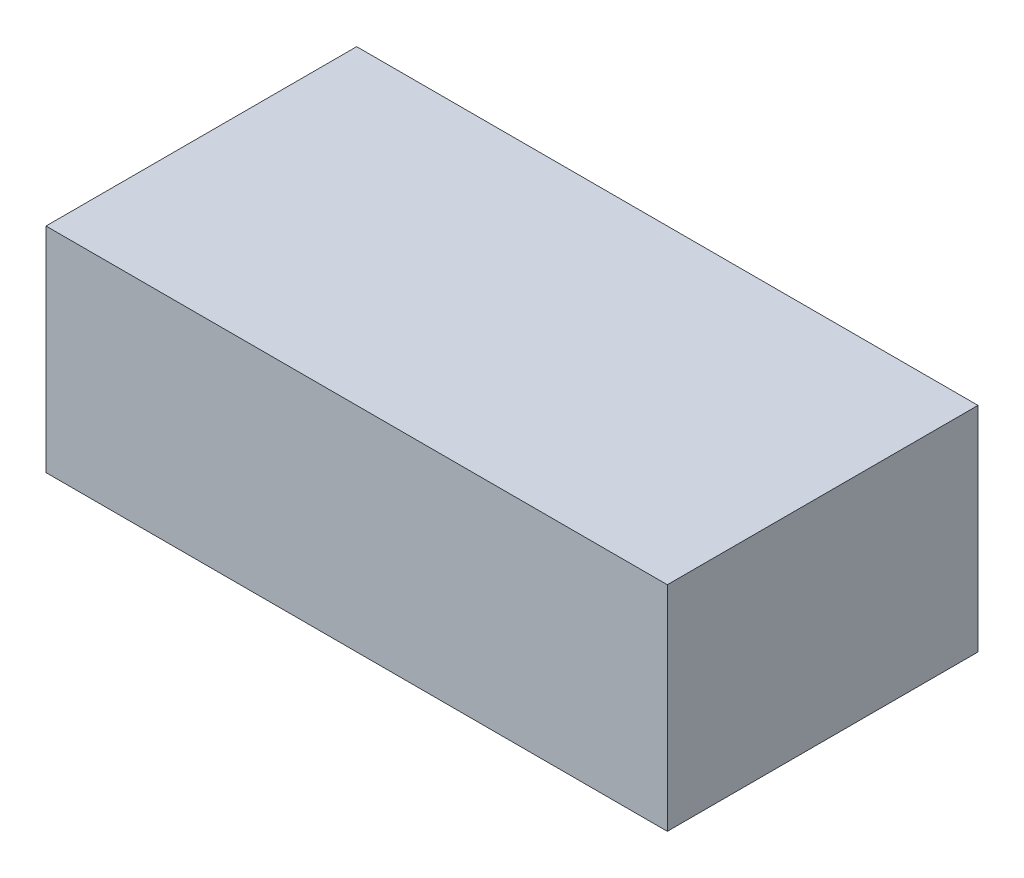
from build123d import *

# Parameters (mm, degrees)
BASES_W    = 1.6
BASES_H    = 0.8
BASE_DEPTH = 0.55


with BuildPart() as part:
    # BaseS → Base (new body)
    with BuildSketch(Plane(origin=(0, 0, 0), x_dir=(1, 0, 0), z_dir=(0, 1, 0))):
        Rectangle(BASES_W, BASES_H)
    extrude(amount=BASE_DEPTH)


solid = part.part
